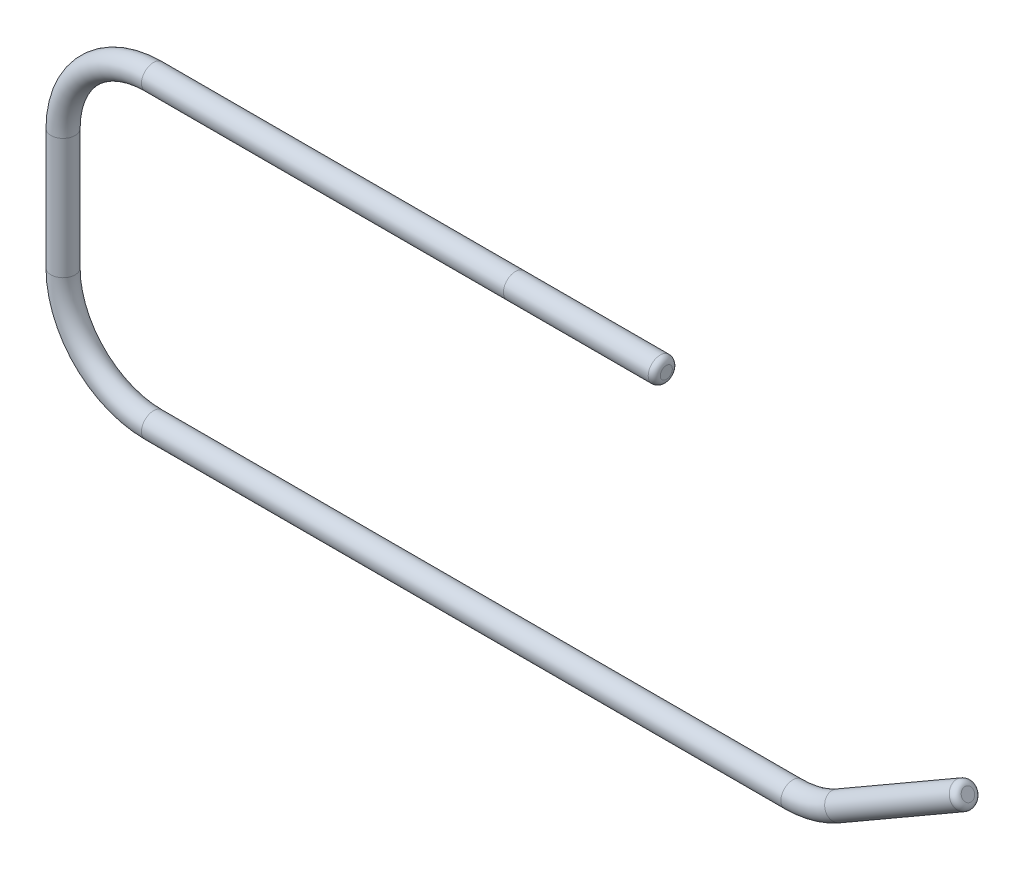
from build123d import *

# Parameters (mm, degrees)
SWEEP1_PROFILE_R = 4
FILLET1_R        = 2


with BuildPart() as part:
    # Sweep1: sweep along a path in Sketch1
    with BuildLine(Plane.XY) as sweep1_path:
        Line((150, -71.132486541), (106.961524227, -95.980762114))
        ThreePointArc((106.961524227, -95.980762114), (99.72609558, -98.977774789), (91.961524227, -100))
        Line((91.961524227, -100), (-120, -100))
        ThreePointArc((-120, -100), (-141.213203436, -91.213203436), (-150, -70))
        Line((-150, -70), (-150, -30))
        ThreePointArc((-150, -30), (-141.213203436, -8.786796564), (-120, 0))
        Line((-120, 0), (0, 0))
        Line((0, 0), (50, 0))
    # Sweep1 profile (on start of the path) → Sweep1 (sweep)
    with BuildSketch(Plane(origin=(150, -71.132486541, 0), x_dir=(0.5, -0.866025404, 0), z_dir=(-0.866025404, -0.5, 0))):
        Circle(SWEEP1_PROFILE_R)
    sweep(path=sweep1_path.line)

    # Fillet1
    fillet1_edges = [part.edges().sort_by_distance(p)[0] for p in [
        (148, -67.668384925, 0),
        (50, -4, 0),
    ]]
    fillet(fillet1_edges, radius=FILLET1_R)


solid = part.part
